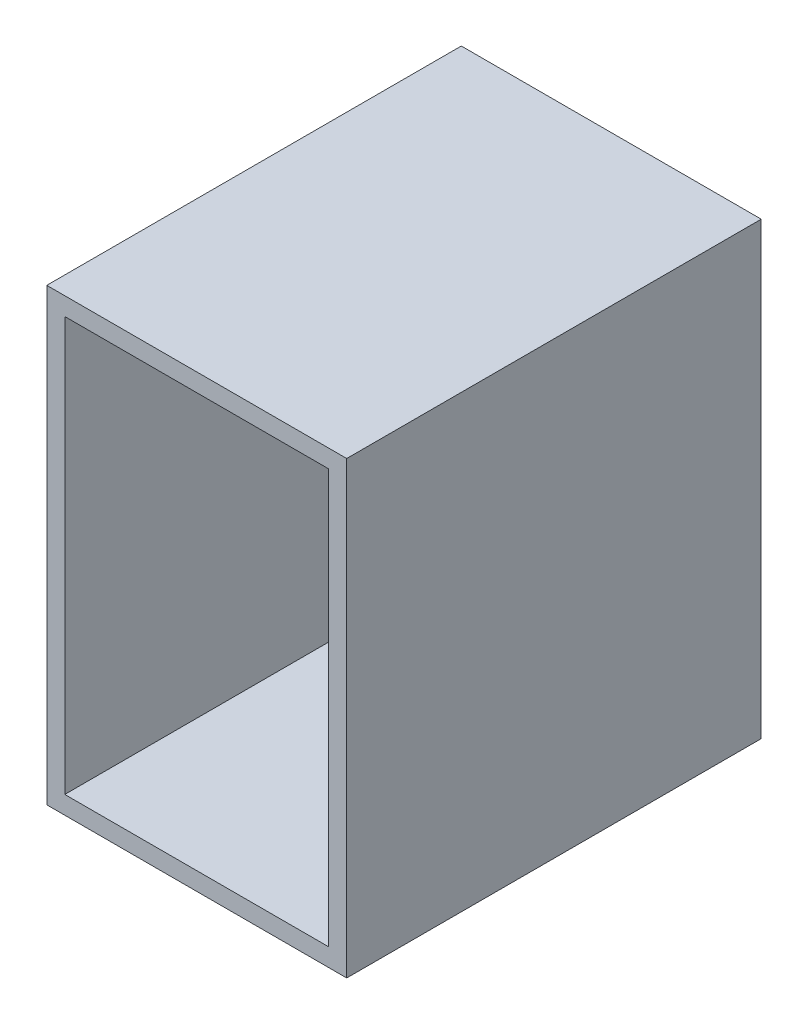
from build123d import *

# Parameters (mm, degrees)
SKETCH1_W           = 100
SKETCH1_H           = 150
SKETCH1_W_2         = 88
SKETCH1_H_2         = 138
BOSS_EXTRUDE1_DEPTH = 138.202315188


with BuildPart() as part:
    # Sketch1 → Boss-Extrude1 (new body)
    with BuildSketch(Plane.XY):
        Rectangle(SKETCH1_W, SKETCH1_H)
        Rectangle(SKETCH1_W_2, SKETCH1_H_2, mode=Mode.SUBTRACT)
    extrude(amount=BOSS_EXTRUDE1_DEPTH)


solid = part.part
